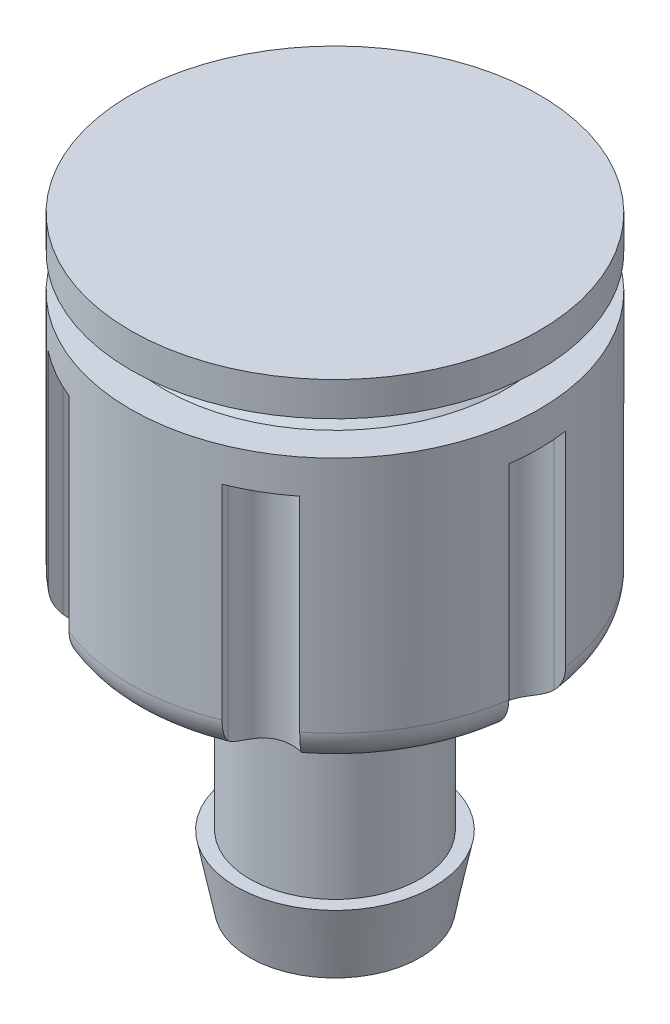
from build123d import *

# Parameters (mm, degrees)
CUT_EXTRUDE1_DEPTH      = 7
CUT_EXTRUDE1_DEPTH_BACK = 7


with BuildPart() as part:
    # Sketch1 → Revolve1 (revolve)
    with BuildSketch(Plane(origin=(0, 0, 0), x_dir=(0, 0, -1), z_dir=(1, 0, 0))):
        with BuildLine():
            Line((0, 0), (6, 0))
            Line((6, 0), (6, -1))
            Line((6, -1), (5, -1))
            Line((5, -1), (4.5, -1.5))
            Line((4.5, -1.5), (5, -2))
            Line((5, -2), (6, -2))
            Line((6, -2), (6, -9))
            ThreePointArc((6, -9), (5.707106781, -9.707106781), (5, -10))
            Line((5, -10), (3, -10))
            Line((3, -10), (2.5, -10.5))
            Line((2.5, -10.5), (2.5, -15.7))
            Line((2.5, -15.7), (2.895480226, -15.7))
            Line((2.895480226, -15.7), (2.5, -17.7))
            Line((2.5, -17.7), (1.5, -17.7))
            Line((1.5, -17.7), (1.5, -10))
            Line((1.5, -10), (0, -10))
            Line((0, -10), (0, 0))
        make_face()
    revolve(axis=Axis((0, -17.7, 0), (0, 1, 0)))

    # Sketch2 → Cut-Extrude1 (cut, two sides)
    with BuildSketch(Plane(origin=(0, -10, 0), x_dir=(-1, 0, 0), z_dir=(0, -1, 0))) as cut_extrude1_sk:
        with BuildLine():
            Line((-1, -14.966629547), (-1, -9.949874371))
            ThreePointArc((-1, -9.949874371), (-2.397127157, -9.708438669), (-3.746065934, -9.271838546))
            Line((-3.746065934, -9.271838546), (-2.13237153, -5.277804741))
            ThreePointArc((-2.13237153, -5.277804741), (-2.474118614, -4.285299143), (-3.504527217, -4.485590286))
            Line((-3.504527217, -4.485590286), (-6.156614753, -7.880107536))
            ThreePointArc((-6.156614753, -7.880107536), (-8.660254038, -5), (-9.902680687, -1.39173101))
            Line((-9.902680687, -1.39173101), (-5.636898747, -0.792214455))
            ThreePointArc((-5.636898747, -0.792214455), (-4.948237227, 0), (-5.636898747, 0.792214455))
            Line((-5.636898747, 0.792214455), (-9.902680687, 1.39173101))
            ThreePointArc((-9.902680687, 1.39173101), (-8.660254038, 5), (-6.156614753, 7.880107536))
            Line((-6.156614753, 7.880107536), (-3.504527217, 4.485590286))
            ThreePointArc((-3.504527217, 4.485590286), (-2.474118614, 4.285299143), (-2.13237153, 5.277804741))
            Line((-2.13237153, 5.277804741), (-3.746065934, 9.271838546))
            ThreePointArc((-3.746065934, 9.271838546), (0, 10), (3.746065934, 9.271838546))
            Line((3.746065934, 9.271838546), (2.13237153, 5.277804741))
            ThreePointArc((2.13237153, 5.277804741), (2.474118614, 4.285299143), (3.504527217, 4.485590286))
            Line((3.504527217, 4.485590286), (6.156614753, 7.880107536))
            ThreePointArc((6.156614753, 7.880107536), (8.660254038, 5), (9.902680687, 1.39173101))
            Line((9.902680687, 1.39173101), (5.636898747, 0.792214455))
            ThreePointArc((5.636898747, 0.792214455), (4.948237227, 0), (5.636898747, -0.792214455))
            Line((5.636898747, -0.792214455), (9.902680687, -1.39173101))
            ThreePointArc((9.902680687, -1.39173101), (8.660254038, -5), (6.156614753, -7.880107536))
            Line((6.156614753, -7.880107536), (3.504527217, -4.485590286))
            ThreePointArc((3.504527217, -4.485590286), (2.474118614, -4.285299143), (2.13237153, -5.277804741))
            Line((2.13237153, -5.277804741), (3.746065934, -9.271838546))
            ThreePointArc((3.746065934, -9.271838546), (1.908089954, -9.816271834), (0, -10))
            Line((0, -10), (0, -15))
            ThreePointArc((0, -15), (0.500278319, 14.991655066), (-1, -14.966629547))
        make_face()
    extrude(amount=CUT_EXTRUDE1_DEPTH, mode=Mode.SUBTRACT)
    extrude(cut_extrude1_sk.sketch, amount=-CUT_EXTRUDE1_DEPTH_BACK, mode=Mode.SUBTRACT)


solid = part.part
